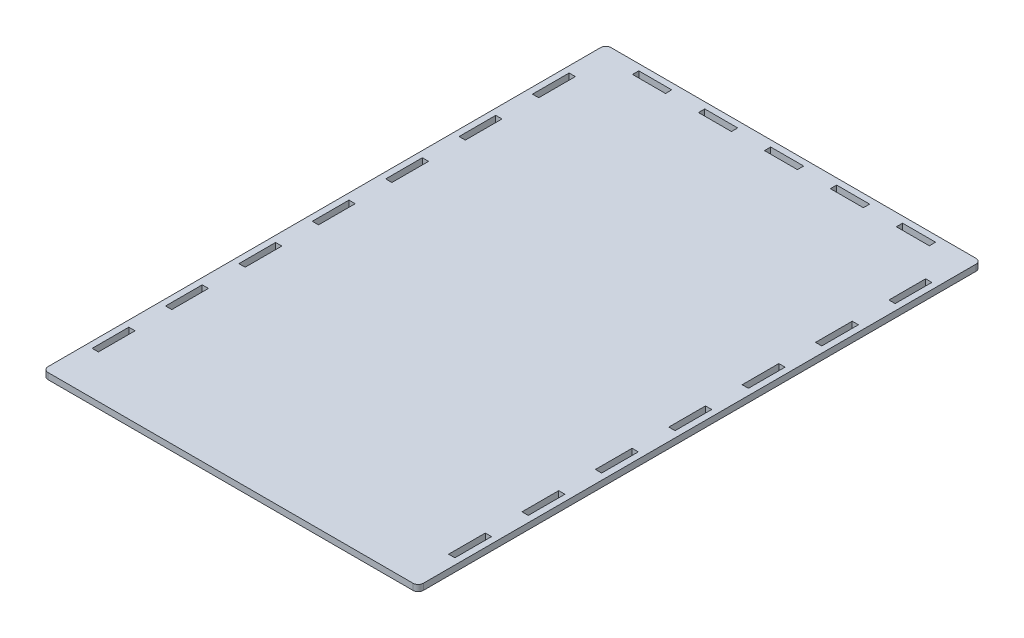
from build123d import *

# Parameters (mm, degrees)
SKETCH1_W               = 180
SKETCH1_H               = 270
BOSS_EXTRUDE1_DEPTH     = 3
SKETCH2_W               = 15.818181818
SKETCH2_H               = 3
SKETCH2_W_2             = 3
SKETCH2_H_2             = 17.6
CUT_EXTRUDE1_DEPTH      = 1
CUT_EXTRUDE1_DEPTH_BACK = 4
FILLET1_R               = 2.5


with BuildPart() as part:
    # Sketch1 → Boss-Extrude1 (new body)
    with BuildSketch(Plane(origin=(0, 0, 0), x_dir=(1, 0, 0), z_dir=(0, 1, 0))):
        Rectangle(SKETCH1_W, SKETCH1_H)
    extrude(amount=BOSS_EXTRUDE1_DEPTH)

    # Sketch2 → Cut-Extrude1 (cut, two sides)
    with BuildSketch(Plane(origin=(0, 3, 0), x_dir=(1, 0, 0), z_dir=(0, 1, 0))) as cut_extrude1_sk:
        with Locations((0, 130.5)):
            Rectangle(SKETCH2_W, SKETCH2_H)
        with Locations((31.636363636, 130.5)):
            Rectangle(SKETCH2_W, SKETCH2_H)
        with Locations((63.272727273, 130.5)):
            Rectangle(SKETCH2_W, SKETCH2_H)
        with Locations((85.5, -70.4)):
            Rectangle(SKETCH2_W_2, SKETCH2_H_2)
        with Locations((-31.636363636, 130.5)):
            Rectangle(SKETCH2_W, SKETCH2_H)
        with Locations((-63.272727273, 130.5)):
            Rectangle(SKETCH2_W, SKETCH2_H)
        with Locations((85.5, -105.6)):
            Rectangle(SKETCH2_W_2, SKETCH2_H_2)
        with Locations((-85.5, 105.6)):
            Rectangle(SKETCH2_W_2, SKETCH2_H_2)
        with Locations((-85.5, 70.4)):
            Rectangle(SKETCH2_W_2, SKETCH2_H_2)
        with Locations((-85.5, 35.2)):
            Rectangle(SKETCH2_W_2, SKETCH2_H_2)
        with Locations((-85.5, 0)):
            Rectangle(SKETCH2_W_2, SKETCH2_H_2)
        with Locations((85.5, 105.6)):
            Rectangle(SKETCH2_W_2, SKETCH2_H_2)
        with Locations((85.5, 70.4)):
            Rectangle(SKETCH2_W_2, SKETCH2_H_2)
        with Locations((85.5, 35.2)):
            Rectangle(SKETCH2_W_2, SKETCH2_H_2)
        with Locations((85.5, 0)):
            Rectangle(SKETCH2_W_2, SKETCH2_H_2)
        with Locations((85.5, -35.2)):
            Rectangle(SKETCH2_W_2, SKETCH2_H_2)
        with Locations((-85.5, -35.2)):
            Rectangle(SKETCH2_W_2, SKETCH2_H_2)
        with Locations((-85.5, -70.4)):
            Rectangle(SKETCH2_W_2, SKETCH2_H_2)
        with Locations((-85.5, -105.6)):
            Rectangle(SKETCH2_W_2, SKETCH2_H_2)
    extrude(amount=CUT_EXTRUDE1_DEPTH, mode=Mode.SUBTRACT)
    extrude(cut_extrude1_sk.sketch, amount=-CUT_EXTRUDE1_DEPTH_BACK, mode=Mode.SUBTRACT)

    # Fillet1
    fillet1_edges = [part.edges().sort_by_distance(p)[0] for p in [
        (90, 1.5, -135),
        (90, 1.5, 135),
        (-90, 1.5, 135),
        (-90, 1.5, -135),
    ]]
    fillet(fillet1_edges, radius=FILLET1_R)


solid = part.part
